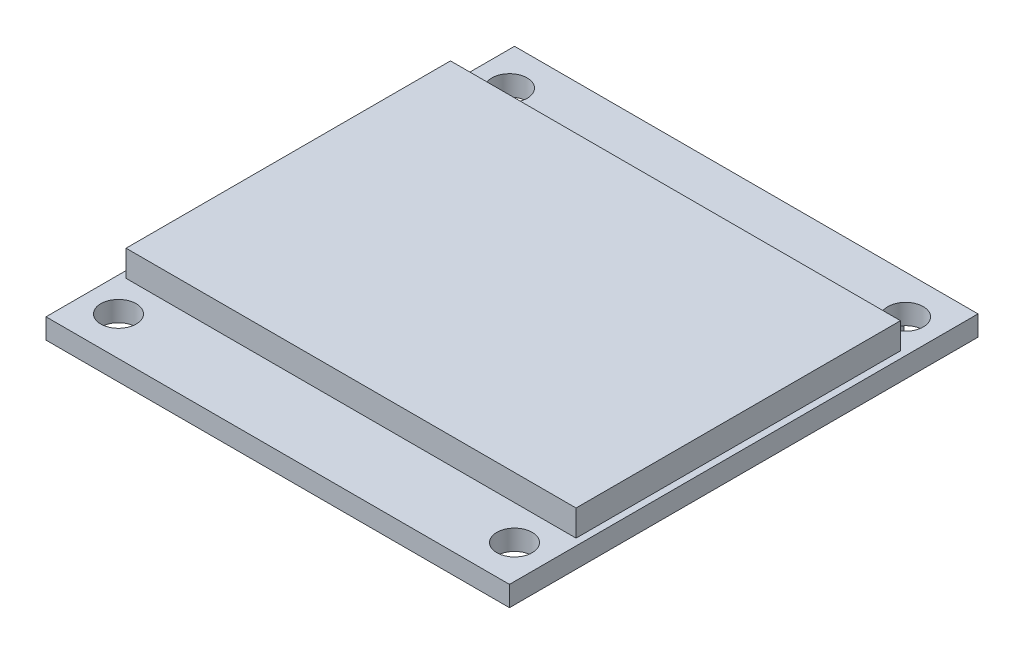
from build123d import *

# Parameters (mm, degrees)
SKETCH1_W           = 27.5
SKETCH1_H           = 27.8
SKETCH1_R           = 1.05
BOSS_EXTRUDE1_DEPTH = 1.2
SKETCH2_W           = 26.7
SKETCH2_H           = 19.25
BOSS_EXTRUDE2_DEPTH = 1.55
SKETCH3_W           = 17.75
SKETCH3_H           = 2.55
BOSS_EXTRUDE3_DEPTH = 2.35


with BuildPart() as part:
    # Sketch1 → Boss-Extrude1 (new body)
    with BuildSketch(Plane(origin=(0, 0, 0), x_dir=(1, 0, 0), z_dir=(0, 1, 0))):
        with Locations((-7.986995643, 4.078730041)):
            Rectangle(SKETCH1_W, SKETCH1_H)
        with Locations((-19.736995643, 15.678730041)):
            Circle(SKETCH1_R, mode=Mode.SUBTRACT)
        with Locations((3.763004357, 15.678730041)):
            Circle(SKETCH1_R, mode=Mode.SUBTRACT)
        with Locations((3.763004357, -7.521269959)):
            Circle(SKETCH1_R, mode=Mode.SUBTRACT)
        with Locations((-19.736995643, -7.521269959)):
            Circle(SKETCH1_R, mode=Mode.SUBTRACT)
    extrude(amount=BOSS_EXTRUDE1_DEPTH)

    # Sketch2 → Boss-Extrude2 (add)
    with BuildSketch(Plane(origin=(0, 1.2, 0), x_dir=(1, 0, 0), z_dir=(0, 1, 0))):
        with Locations((-7.986995643, 4.153730041)):
            Rectangle(SKETCH2_W, SKETCH2_H)
    extrude(amount=BOSS_EXTRUDE2_DEPTH)

    # Sketch3 → Boss-Extrude3 (add)
    with BuildSketch(Plane.XZ):
        with Locations((-7.256318238, -16.453730041)):
            Rectangle(SKETCH3_W, SKETCH3_H)
    extrude(amount=BOSS_EXTRUDE3_DEPTH)


solid = part.part
